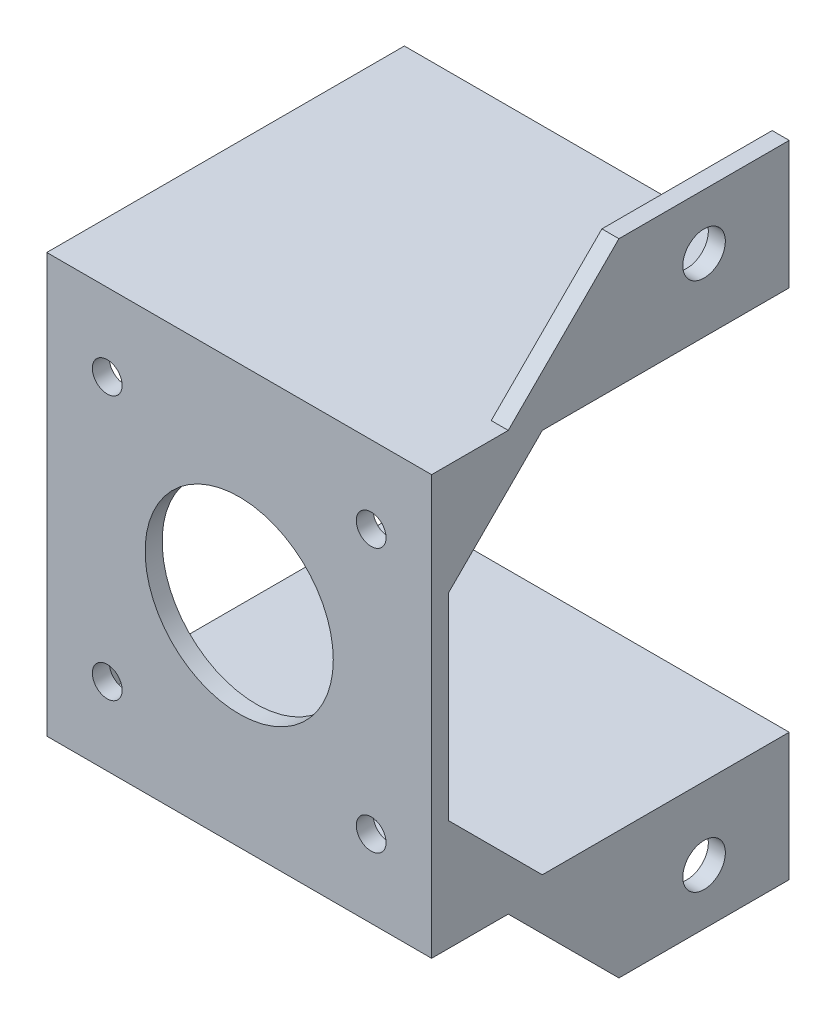
from build123d import *

# Parameters (mm, degrees)
SKETCH1_W           = 45.2
SKETCH1_H           = 45.2
SKETCH1_R           = 1.75
SKETCH1_R_2         = 11.05
BOSS_EXTRUDE1_DEPTH = 2
SKETCH3_W           = 45.2
SKETCH3_H           = 2
BOSS_EXTRUDE2_DEPTH = 42
SKETCH4_W           = 20
SKETCH4_H           = 13
SKETCH4_R           = 2.5
BOSS_EXTRUDE3_DEPTH = 2
BOSS_EXTRUDE4_DEPTH = 1
BOSS_EXTRUDE5_DEPTH = 1


with BuildPart() as part:
    # Sketch1 → Boss-Extrude1 (new body)
    with BuildSketch(Plane.XY):
        Rectangle(SKETCH1_W, SKETCH1_H)
        with Locations((-15.5, 15.5)):
            Circle(SKETCH1_R, mode=Mode.SUBTRACT)
        with Locations((15.5, 15.5)):
            Circle(SKETCH1_R, mode=Mode.SUBTRACT)
        with Locations((-15.5, -15.5)):
            Circle(SKETCH1_R, mode=Mode.SUBTRACT)
        with Locations((15.5, -15.5)):
            Circle(SKETCH1_R, mode=Mode.SUBTRACT)
        Circle(SKETCH1_R_2, mode=Mode.SUBTRACT)
    extrude(amount=BOSS_EXTRUDE1_DEPTH)

    # Sketch3 → Boss-Extrude2 (add)
    with BuildSketch(Plane.XY.offset(2)):
        with Locations((0, 23.6)):
            Rectangle(SKETCH3_W, SKETCH3_H)
    boss_extrude2 = extrude(amount=-BOSS_EXTRUDE2_DEPTH)

    # Sketch4 → Boss-Extrude3 (add)
    with BuildSketch(Plane(origin=(22.6, 0, 0), x_dir=(0, 0, -1), z_dir=(1, 0, 0))):
        Polygon((7, 24.6), (20, 24.6), (20, 37.6), align=None)
        with Locations((30, 31.1)):
            Rectangle(SKETCH4_W, SKETCH4_H)
        with Locations((30, 31.1)):
            Circle(SKETCH4_R, mode=Mode.SUBTRACT)
    boss_extrude3 = extrude(amount=-BOSS_EXTRUDE3_DEPTH)

    # Mirror1: Boss-Extrude2, Boss-Extrude3 across plane
    add(boss_extrude2.mirror(Plane.ZX))
    add(boss_extrude3.mirror(Plane.ZX))

    # Sketch5 → Boss-Extrude4 (add)
    with BuildSketch(Plane.ZY.offset(22.6)):
        Polygon((-13, 24.6), (2, 9.6), (2, 24.6), align=None)
        Polygon((-13, -24.6), (2, -9.6), (2, -24.6), align=None)
    extrude(amount=-BOSS_EXTRUDE4_DEPTH)

    # Sketch6 → Boss-Extrude5 (add)
    with BuildSketch(Plane(origin=(22.6, 0, 0), x_dir=(0, 0, -1), z_dir=(1, 0, 0))):
        Polygon((-2, 9.6), (13, 24.6), (-2, 24.6), align=None)
        Polygon((13, -24.6), (-2, -9.6), (-2, -24.6), align=None)
    extrude(amount=-BOSS_EXTRUDE5_DEPTH)


solid = part.part
